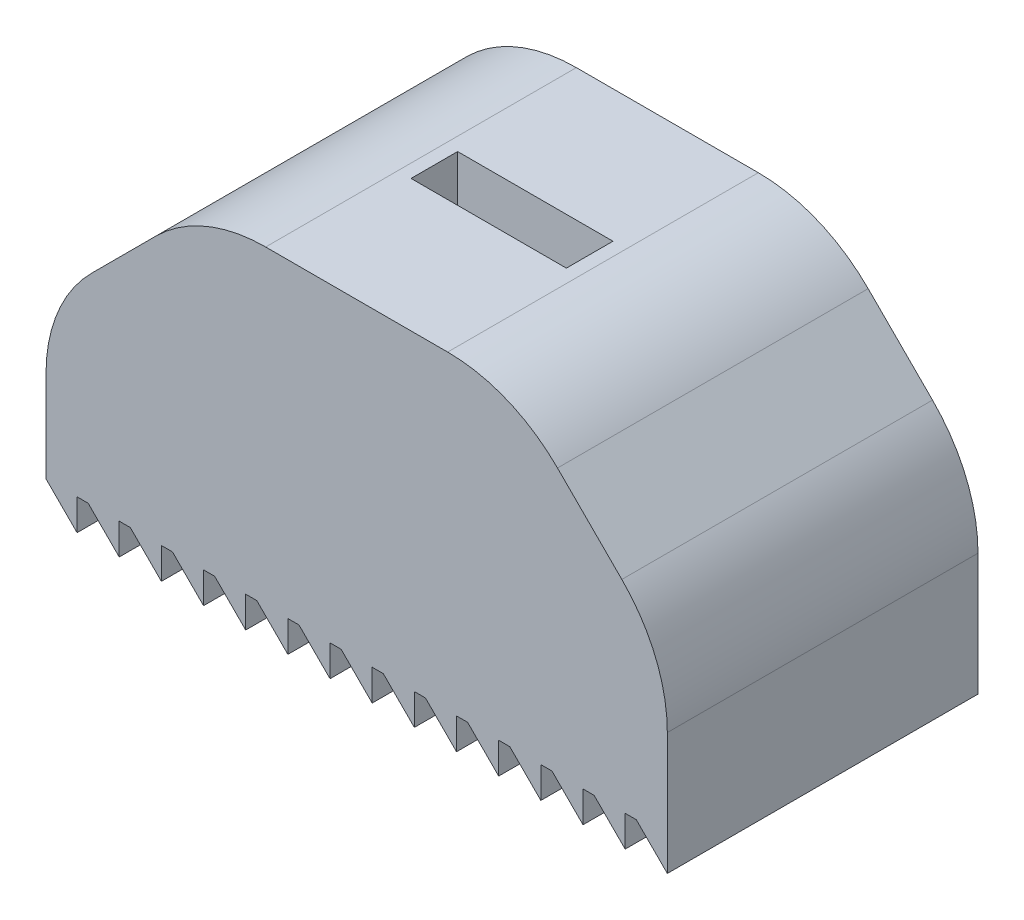
from build123d import *

# Parameters (mm, degrees)
BOSS_EXTRUDE1_DEPTH = 20
SKETCH2_W           = 10
SKETCH2_H           = 3
CUT_EXTRUDE1_DEPTH  = 10
FILLET_1_R          = 10


with BuildPart() as part:
    # Sketch1 → Boss-Extrude1 (new body)
    with BuildSketch(Plane.XY):
        Polygon((17.014668726, -22), (17.014668726, -20), (17.728954441, -20), (19.728954441, -22), (19.728954441, -20), (19.728954441, -10), (9.728954441, 0), (-10.271045559, 0), (-20.271045559, -10), (-20.271045559, -20), (-18.271045559, -22), (-18.271045559, -20), (-17.556759845, -20), (-15.556759845, -22), (-15.556759845, -20), (-14.842474131, -20), (-12.842474131, -22), (-12.842474131, -20), (-12.128188417, -20), (-10.128188417, -22), (-10.128188417, -20), (-9.413902702, -20), (-7.413902702, -22), (-7.413902702, -20), (-6.699616988, -20), (-4.699616988, -22), (-4.699616988, -20), (-3.985331274, -20), (-1.985331274, -22), (-1.985331274, -20), (-1.271045559, -20), (0.728954441, -22), (0.728954441, -20), (1.443240155, -20), (3.443240155, -22), (3.443240155, -20), (4.157525869, -20), (6.157525869, -22), (6.157525869, -20), (6.871811583, -20), (8.871811583, -22), (8.871811583, -20), (9.586097298, -20), (11.586097298, -22), (11.586097298, -20), (12.300383012, -20), (14.300383012, -22), (14.300383012, -20), (15.014668726, -20), align=None)
    extrude(amount=BOSS_EXTRUDE1_DEPTH)

    # Sketch2 → Cut-Extrude1 (cut)
    with BuildSketch(Plane(origin=(0, 0, 0), x_dir=(1, 0, 0), z_dir=(0, 1, 0))):
        with Locations((-0.271045559, -10)):
            Rectangle(SKETCH2_W, SKETCH2_H)
    extrude(amount=-CUT_EXTRUDE1_DEPTH, mode=Mode.SUBTRACT)

    # Скругление1
    fillet_1_edges = [part.edges().sort_by_distance(p)[0] for p in [
        (-20.271045559, -10, 10),
        (-10.271045559, 0, 10),
        (9.728954441, 0, 10),
        (19.728954441, -10, 10),
    ]]
    fillet(fillet_1_edges, radius=FILLET_1_R)


solid = part.part
